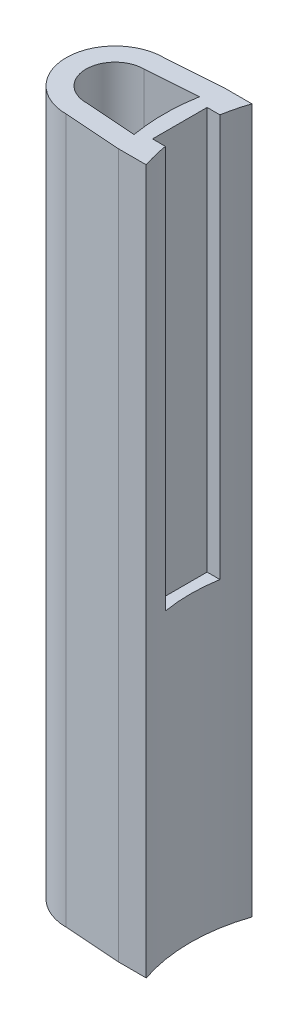
from build123d import *

# Parameters (mm, degrees)
BOSS_EXTRUDE1_DEPTH = 40
CUT_EXTRUDE1_DEPTH  = 22.857142857


with BuildPart() as part:
    # Sketch2 → Boss-Extrude1 (new body)
    with BuildSketch(Plane(origin=(0, 0, 0), x_dir=(1, 0, 0), z_dir=(0, 1, 0))):
        with BuildLine():
            Line((0, 2.775), (3.1979918, 3))
            Line((3.1979918, 3), (4.769352085, 3))
            ThreePointArc((4.769352085, 3), (4.275, 0), (4.769352085, -3))
            Line((4.769352085, -3), (3.1979918, -3))
            Line((3.1979918, -3), (0, -2.775))
            ThreePointArc((0, -2.775), (-2.775, 0), (0, 2.775))
        make_face()
        with BuildLine():
            Line((0, 1.65), (2.935008537, 1.856497378))
            ThreePointArc((2.935008537, 1.856497378), (2.775, 0), (2.935008537, -1.856497378))
            Line((2.935008537, -1.856497378), (0, -1.65))
            ThreePointArc((0, -1.65), (-1.65, 0), (0, 1.65))
        make_face(mode=Mode.SUBTRACT)
    extrude(amount=BOSS_EXTRUDE1_DEPTH)

    # Sketch3 → Cut-Extrude1 (cut)
    with BuildSketch(Plane(origin=(0, 40, 0), x_dir=(1, 0, 0), z_dir=(0, 1, 0))):
        with BuildLine():
            Line((3.675, 1.55), (4.404370954, 1.55))
            ThreePointArc((4.404370954, 1.55), (4.275, 0), (4.404370954, -1.55))
            Line((4.404370954, -1.55), (3.675, -1.55))
            Line((3.675, -1.55), (3.675, 1.55))
        make_face()
    extrude(amount=-CUT_EXTRUDE1_DEPTH, mode=Mode.SUBTRACT)


solid = part.part
